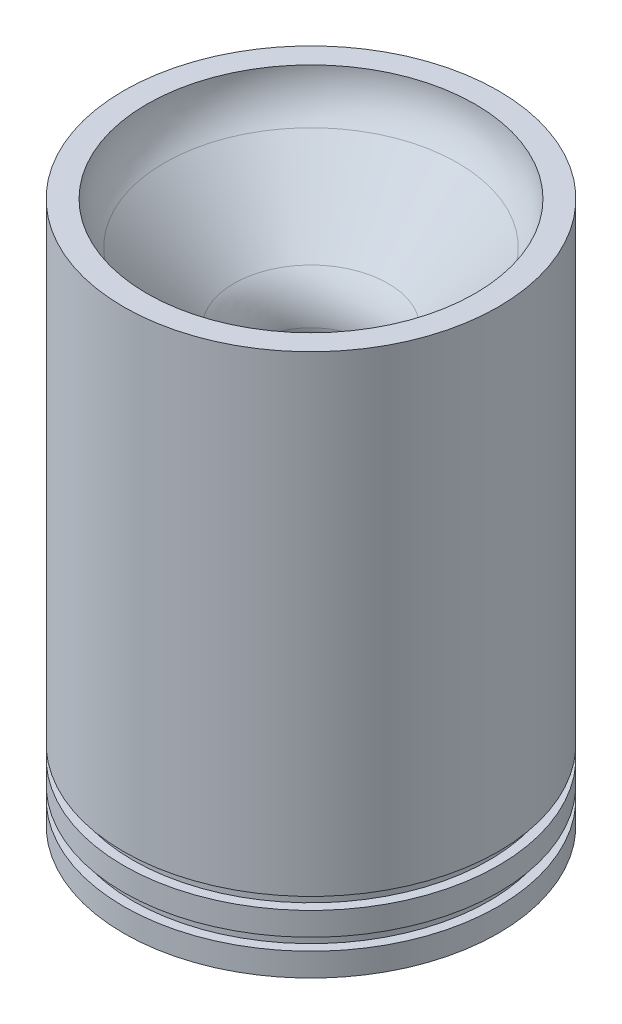
from build123d import *


with BuildPart() as part:
    # Sketch1 → Revolve1 (revolve)
    with BuildSketch(Plane.XY):
        with BuildLine():
            Line((-51.1302, 0), (-51.1302, -128.764609009))
            Line((-51.1302, -128.764609009), (-48.5902, -128.764609009))
            Line((-48.5902, -128.764609009), (-48.5902, -132.066609009))
            Line((-48.5902, -132.066609009), (-51.1302, -132.066609009))
            Line((-51.1302, -132.066609009), (-51.1302, -138.416609009))
            Line((-51.1302, -138.416609009), (-48.5902, -138.416609009))
            Line((-48.5902, -138.416609009), (-48.5902, -141.718609009))
            Line((-48.5902, -141.718609009), (-51.1302, -141.718609009))
            Line((-51.1302, -141.718609009), (-51.1302, -148.068609009))
            Line((-51.1302, -148.068609009), (-44.45, -148.068609009))
            Line((-44.45, -148.068609009), (-16.477563907, -43.674056299))
            ThreePointArc((-16.477563907, -43.674056299), (-16.311628933, -42.839844852), (-16.256, -41.99111134))
            ThreePointArc((-16.256, -41.99111134), (-17.493414319, -35.770209463), (-21.017272165, -30.496383505))
            Line((-21.017272165, -30.496383505), (-40.018927835, -11.494727835))
            ThreePointArc((-40.018927835, -11.494727835), (-43.542785681, -6.220901877), (-44.7802, 0))
            Line((-44.7802, 0), (-51.1302, 0))
        make_face()
    revolve(axis=Axis((0, 0, 0), (0, -1, 0)))


solid = part.part
